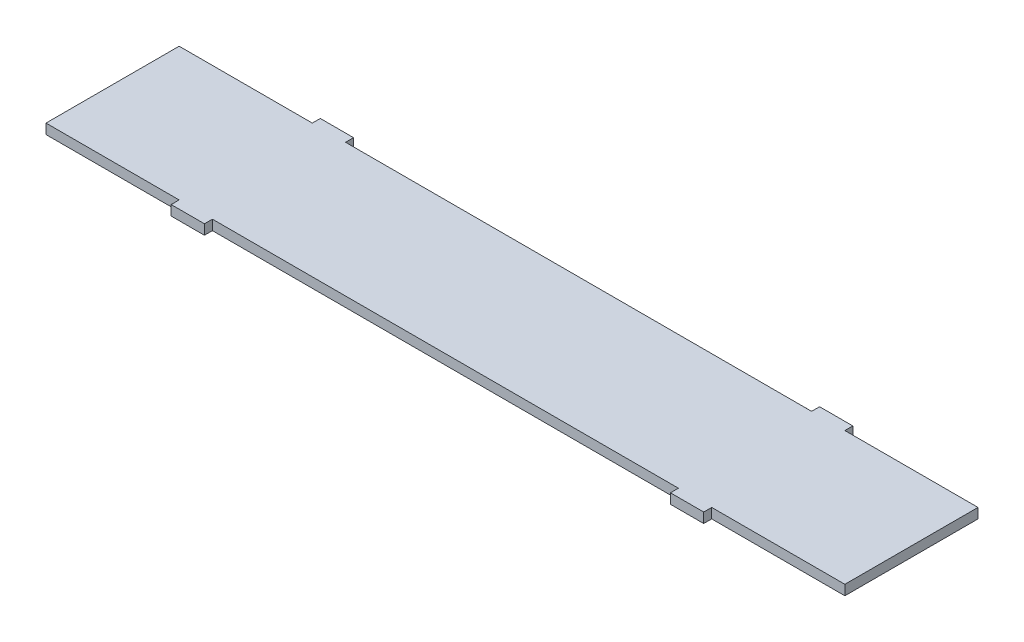
from build123d import *

# Parameters (mm, degrees)
CROQUIS1_W              = 1200
CROQUIS1_H              = 200
SALIENTE_EXTRUIR1_DEPTH = 15
CROQUIS3_W              = 50
CROQUIS3_H              = 12
SALIENTE_EXTRUIR2_DEPTH = 15


with BuildPart() as part:
    # Croquis1 → Saliente-Extruir1 (new body)
    with BuildSketch(Plane(origin=(0, 0, 0), x_dir=(1, 0, 0), z_dir=(0, 1, 0))):
        Rectangle(CROQUIS1_W, CROQUIS1_H)
    extrude(amount=SALIENTE_EXTRUIR1_DEPTH)

    # Croquis3 → Saliente-Extruir2 (add)
    with BuildSketch(Plane(origin=(0, 0, 0), x_dir=(1, 0, 0), z_dir=(0, 1, 0))):
        with Locations((-375, 106)):
            Rectangle(CROQUIS3_W, CROQUIS3_H)
        with Locations((-375, -106)):
            Rectangle(CROQUIS3_W, CROQUIS3_H)
        with Locations((375, -106)):
            Rectangle(CROQUIS3_W, CROQUIS3_H)
        with Locations((375, 106)):
            Rectangle(CROQUIS3_W, CROQUIS3_H)
    extrude(amount=SALIENTE_EXTRUIR2_DEPTH)


solid = part.part
